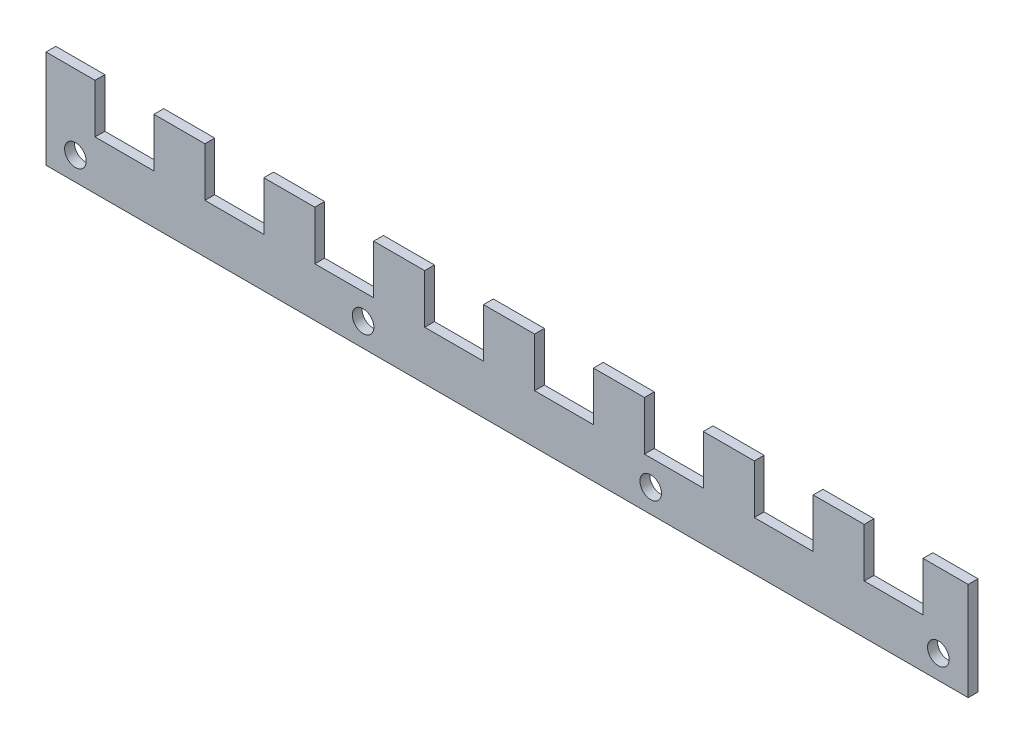
from build123d import *

# Parameters (mm, degrees)
PLAT_W                      = 50
PLAT_H                      = 5
EL_MENT_M_CANO_SOUD_1_DEPTH = 470
ESQUISSE7_W                 = 30
ESQUISSE7_H                 = 25
ENL_V_MAT_EXTRU_2_DEPTH     = 6
R_P_TITION_LIN_AIRE2_COUNT  = 8
R_P_TITION_LIN_AIRE2_PITCH  = 56
ESQUISSE8_R                 = 5.5
ENL_V_MAT_EXTRU_3_DEPTH     = 5
R_P_TITION_LIN_AIRE3_COUNT  = 4
R_P_TITION_LIN_AIRE3_PITCH  = 146.6


with BuildPart() as part:
    # plat → Elément mécano-soudé1 (new body)
    with BuildSketch(Plane.YZ.offset(-235)):
        Rectangle(PLAT_W, PLAT_H)
    extrude(amount=EL_MENT_M_CANO_SOUD_1_DEPTH)

    # Esquisse7 → Enlèv. mat.-Extru.2 (cut, through all)
    with BuildSketch(Plane.XY.offset(2.5)):
        with Locations((-195, 12.5)):
            Rectangle(ESQUISSE7_W, ESQUISSE7_H)
    enl_v_mat_extru_2 = extrude(amount=-ENL_V_MAT_EXTRU_2_DEPTH, mode=Mode.SUBTRACT)

    # Répétition linéaire2: Enlèv. mat.-Extru.2 ×8
    with Locations(*[(i * R_P_TITION_LIN_AIRE2_PITCH, 0, 0) for i in range(1, R_P_TITION_LIN_AIRE2_COUNT)]):
        add(enl_v_mat_extru_2, mode=Mode.SUBTRACT)

    # Esquisse8 → Enlèv. mat.-Extru.3 (cut, symmetric)
    with BuildSketch(Plane.XY):
        with Locations((-220, -13)):
            Circle(ESQUISSE8_R)
    enl_v_mat_extru_3 = extrude(amount=ENL_V_MAT_EXTRU_3_DEPTH, both=True, mode=Mode.SUBTRACT)

    # Répétition linéaire3: Enlèv. mat.-Extru.3 ×4
    with Locations(*[(i * R_P_TITION_LIN_AIRE3_PITCH, 0, 0) for i in range(1, R_P_TITION_LIN_AIRE3_COUNT)]):
        add(enl_v_mat_extru_3, mode=Mode.SUBTRACT)


solid = part.part
